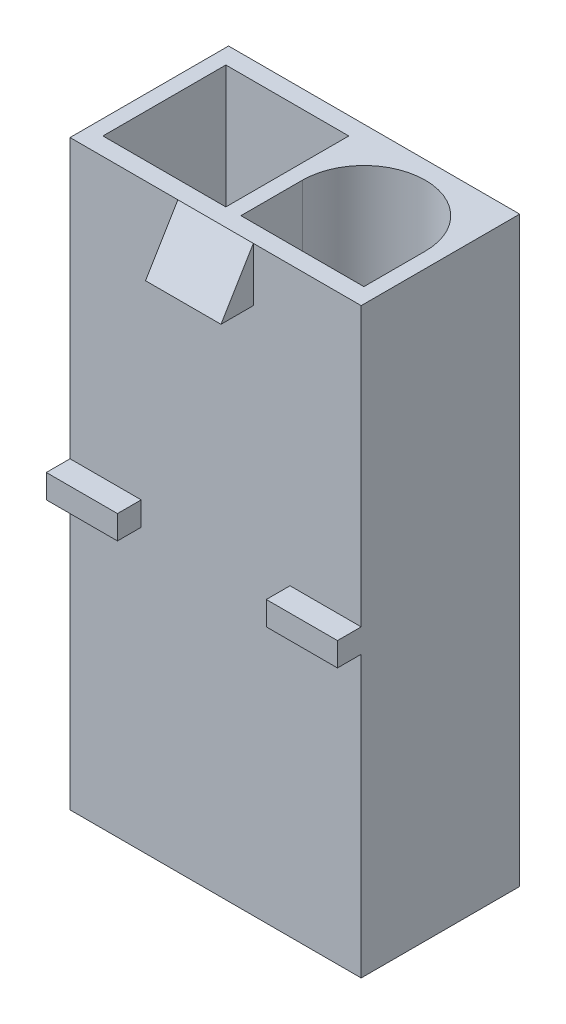
from build123d import *

# Parameters (mm, degrees)
SKETCH1_W                = 13.5
SKETCH1_H                = 27
MAIN_DEPTH               = 3.675
SKETCH2_R                = 2.75
BACKCABLEHOLE_DEPTH      = 8.5
SKETCH3_W                = 5.7
SKETCH3_H                = 5.7
FRONTCONNECTORHOLE_DEPTH = 8.5
MAINHOOK_DEPTH           = 1.75
SKETCH5_W                = 1.1
SKETCH5_H                = 1.1
BOTTOMLINE_DEPTH         = 4.5
SKETCH6_W                = 3.3
SKETCH6_H                = 1.1
SIDEHOOK_DEPTH           = 1.1


with BuildPart() as part:
    # Sketch1 → Main (new body, symmetric)
    with BuildSketch(Plane.XY):
        Rectangle(SKETCH1_W, SKETCH1_H)
    extrude(amount=MAIN_DEPTH, both=True)

    # Sketch2 → BackCableHole (cut)
    with BuildSketch(Plane(origin=(0, -13.5, 0), x_dir=(-1, 0, 0), z_dir=(0, -1, 0))):
        with Locations((3, 0)):
            Circle(SKETCH2_R)
        with Locations((-3, 0)):
            Circle(SKETCH2_R)
    extrude(amount=-BACKCABLEHOLE_DEPTH, mode=Mode.SUBTRACT)

    # Sketch3 → FrontConnectorHole (cut)
    with BuildSketch(Plane(origin=(0, 13.5, 0), x_dir=(1, 0, 0), z_dir=(0, 1, 0))):
        with Locations((-3.2, 0)):
            Rectangle(SKETCH3_W, SKETCH3_H)
        with BuildLine():
            Line((6.05, -2.85), (0.35, -2.85))
            Line((0.35, -2.85), (0.35, 0))
            ThreePointArc((0.35, 0), (3.2, 2.85), (6.05, 0))
            Line((6.05, 0), (6.05, -2.85))
        make_face()
    extrude(amount=-FRONTCONNECTORHOLE_DEPTH, mode=Mode.SUBTRACT)

    # Sketch4 → MainHook (add, symmetric)
    with BuildSketch(Plane(origin=(0, 0, 0), x_dir=(0, 0, -1), z_dir=(1, 0, 0))):
        Polygon((-3.675, 13.5), (-5.175, 11), (-3.675, 11), align=None)
    extrude(amount=MAINHOOK_DEPTH, both=True)

    # Sketch5 → BottomLine (add, symmetric)
    with BuildSketch(Plane(origin=(0, 0, 0), x_dir=(0, 0, -1), z_dir=(1, 0, 0))):
        with Locations((4.225, 0.35)):
            Rectangle(SKETCH5_W, SKETCH5_H)
    extrude(amount=BOTTOMLINE_DEPTH, both=True)

    # Sketch6 → SideHook (add)
    with BuildSketch(Plane.XY.offset(3.675)):
        with Locations((-5.1, 0.05)):
            Rectangle(SKETCH6_W, SKETCH6_H)
        with Locations((5.1, 0.05)):
            Rectangle(SKETCH6_W, SKETCH6_H)
    extrude(amount=SIDEHOOK_DEPTH)


solid = part.part
